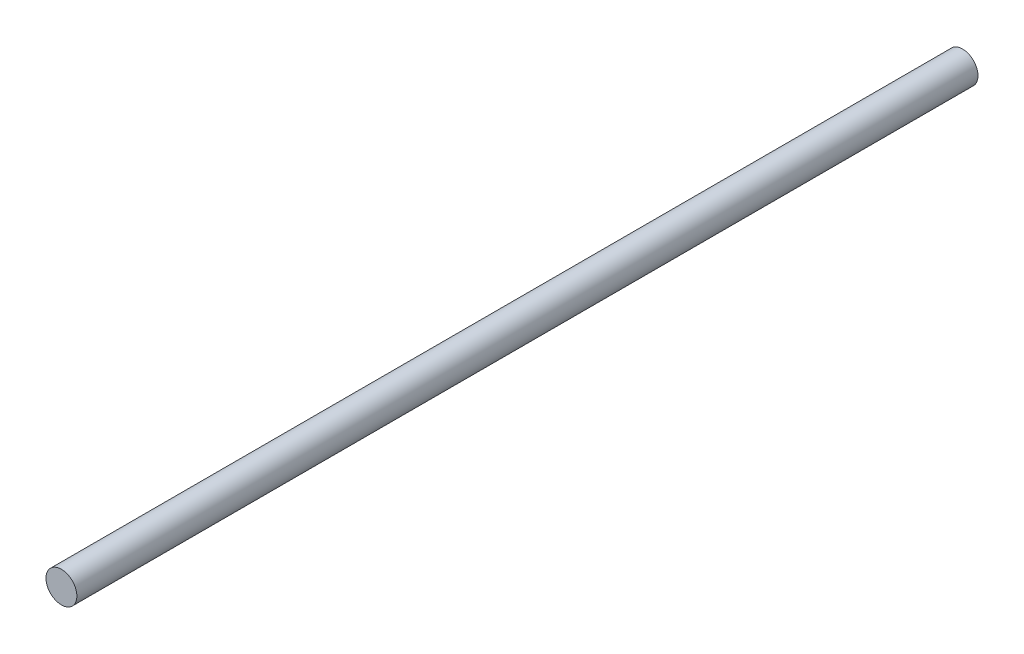
from build123d import *

# Parameters (mm, degrees)
SKETCH1_R           = 6
BOSS_EXTRUDE1_DEPTH = 350


with BuildPart() as part:
    # Sketch1 → Boss-Extrude1 (new body)
    with BuildSketch(Plane.XY):
        Circle(SKETCH1_R)
    extrude(amount=BOSS_EXTRUDE1_DEPTH)


solid = part.part
